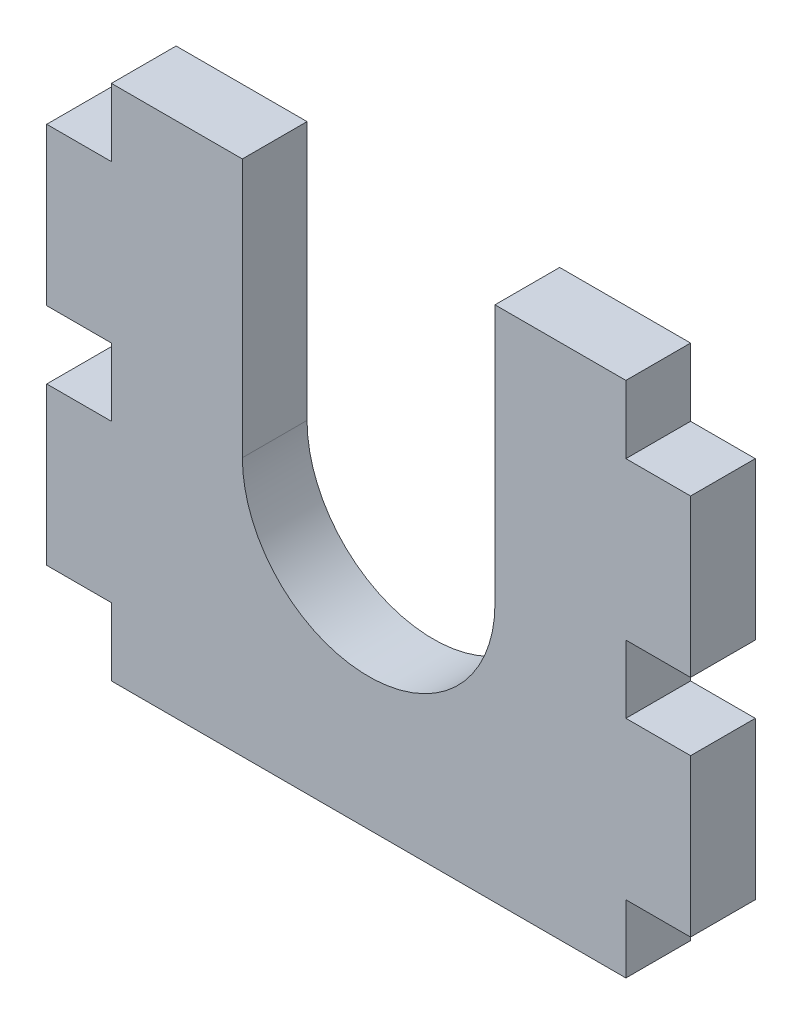
from build123d import *

# Parameters (mm, degrees)
SKETCH1_W           = 53.086
SKETCH1_H           = 42.672
BOSS_EXTRUDE1_DEPTH = 5.334
SKETCH2_W           = 5.334
SKETCH2_H           = 5.588
CUT_EXTRUDE1_DEPTH  = 6.334
SKETCH3_W           = 5.334
SKETCH3_H           = 5.588
CUT_EXTRUDE2_DEPTH  = 6.334
SKETCH4_W           = 5.334
SKETCH4_H           = 5.588
CUT_EXTRUDE3_DEPTH  = 6.334
SKETCH5_W           = 5.334
SKETCH5_H           = 5.588
CUT_EXTRUDE4_DEPTH  = 6.334
SKETCH6_W           = 5.334
SKETCH6_H           = 5.588
CUT_EXTRUDE5_DEPTH  = 6.334
CUT_EXTRUDE6_DEPTH  = 6.334


with BuildPart() as part:
    # Sketch1 → Boss-Extrude1 (new body)
    with BuildSketch(Plane.XY):
        with Locations((26.543, 21.336)):
            Rectangle(SKETCH1_W, SKETCH1_H)
    extrude(amount=BOSS_EXTRUDE1_DEPTH)

    # Sketch2 → Cut-Extrude1 (cut, through all)
    with BuildSketch(Plane.XY.offset(5.334)):
        with Locations((2.667, 39.878)):
            Rectangle(SKETCH2_W, SKETCH2_H)
    extrude(amount=-CUT_EXTRUDE1_DEPTH, mode=Mode.SUBTRACT)

    # Sketch3 → Cut-Extrude2 (cut, through all)
    with BuildSketch(Plane.XY.offset(5.334)):
        with Locations((2.667, 21.336)):
            Rectangle(SKETCH3_W, SKETCH3_H)
    extrude(amount=-CUT_EXTRUDE2_DEPTH, mode=Mode.SUBTRACT)

    # Sketch4 → Cut-Extrude3 (cut, through all)
    with BuildSketch(Plane.XY.offset(5.334)):
        with Locations((2.667, 2.794)):
            Rectangle(SKETCH4_W, SKETCH4_H)
    extrude(amount=-CUT_EXTRUDE3_DEPTH, mode=Mode.SUBTRACT)

    # Sketch5 → Cut-Extrude4 (cut, through all)
    with BuildSketch(Plane.XY.offset(5.334)):
        with Locations((50.419, 39.878)):
            Rectangle(SKETCH5_W, SKETCH5_H)
    extrude(amount=-CUT_EXTRUDE4_DEPTH, mode=Mode.SUBTRACT)

    # Sketch6 → Cut-Extrude5 (cut, through all)
    with BuildSketch(Plane.XY.offset(5.334)):
        with Locations((50.419, 21.336)):
            Rectangle(SKETCH6_W, SKETCH6_H)
        with Locations((50.419, 2.794)):
            Rectangle(SKETCH6_W, SKETCH6_H)
    extrude(amount=-CUT_EXTRUDE5_DEPTH, mode=Mode.SUBTRACT)

    # Sketch11 → Cut-Extrude6 (cut, through all)
    with BuildSketch(Plane.XY.offset(5.334)):
        with BuildLine():
            Line((16.129, 21.336), (16.129, 42.672))
            Line((16.129, 42.672), (36.957, 42.672))
            Line((36.957, 42.672), (36.957, 21.336))
            ThreePointArc((36.957, 21.336), (26.543, 10.922), (16.129, 21.336))
        make_face()
    extrude(amount=-CUT_EXTRUDE6_DEPTH, mode=Mode.SUBTRACT)


solid = part.part
